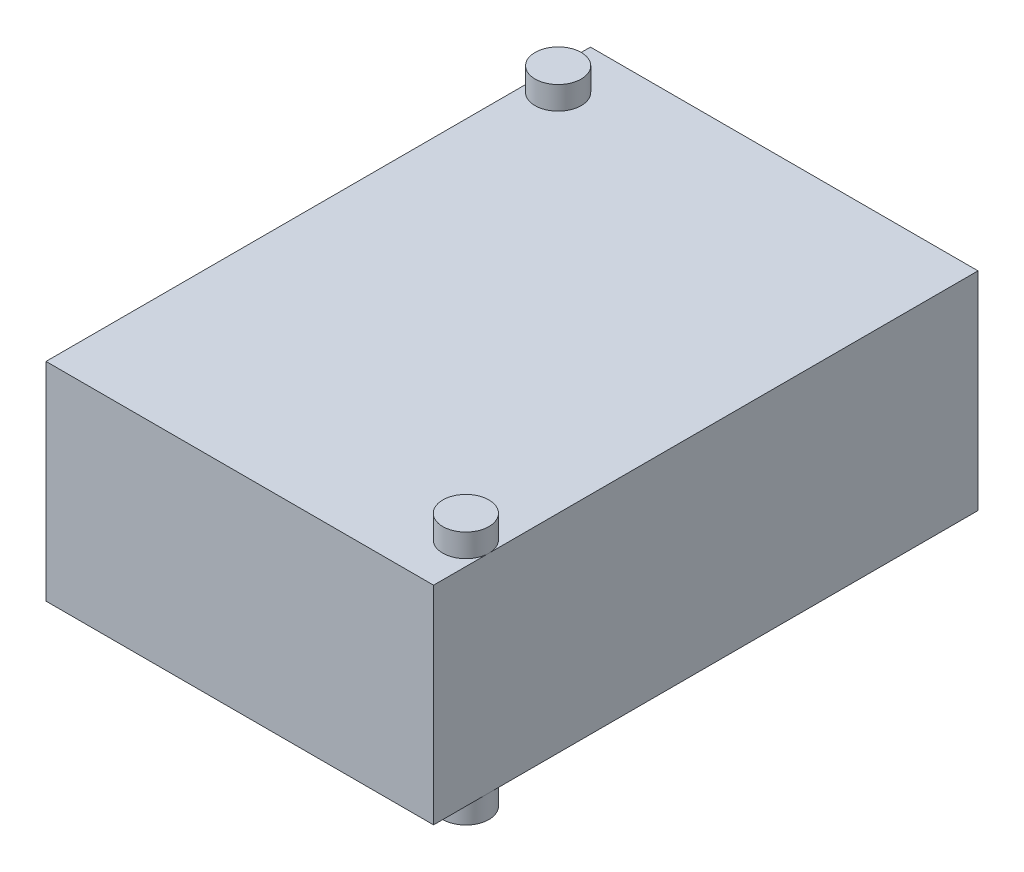
from build123d import *

# Parameters (mm, degrees)
ESQUISSE1_W             = 8.4
ESQUISSE1_H             = 4.5
BOSS_EXTRU_1_DEPTH      = 5.9
BOSS_EXTRU_1_DEPTH_BACK = 5.9
ESQUISSE2_R             = 0.5
BOSS_EXTRU_2_DEPTH      = 0.5
BOSS_EXTRU_2_DEPTH_BACK = 5


with BuildPart() as part:
    # Esquisse1 → Boss.-Extru.1 (new body, two sides)
    with BuildSketch(Plane.XY) as boss_extru_1_sk:
        with Locations((0, 2.25)):
            Rectangle(ESQUISSE1_W, ESQUISSE1_H)
    extrude(amount=BOSS_EXTRU_1_DEPTH)
    extrude(boss_extru_1_sk.sketch, amount=-BOSS_EXTRU_1_DEPTH_BACK)

    # Esquisse2 → Boss.-Extru.2 (add, two sides)
    with BuildSketch(Plane(origin=(0, 4.5, 0), x_dir=(1, 0, 0), z_dir=(0, 1, 0))) as boss_extru_2_sk:
        with Locations(Location((-3.7, 4.7, 0), (0, 0, 180))):  # turned: the seam where the file's is
            Circle(ESQUISSE2_R)
        with Locations(Location((3.7, -4.7, 0), (0, 0, 180))):  # turned: the seam where the file's is
            Circle(ESQUISSE2_R)
    extrude(amount=BOSS_EXTRU_2_DEPTH)
    extrude(boss_extru_2_sk.sketch, amount=-BOSS_EXTRU_2_DEPTH_BACK)


solid = part.part
